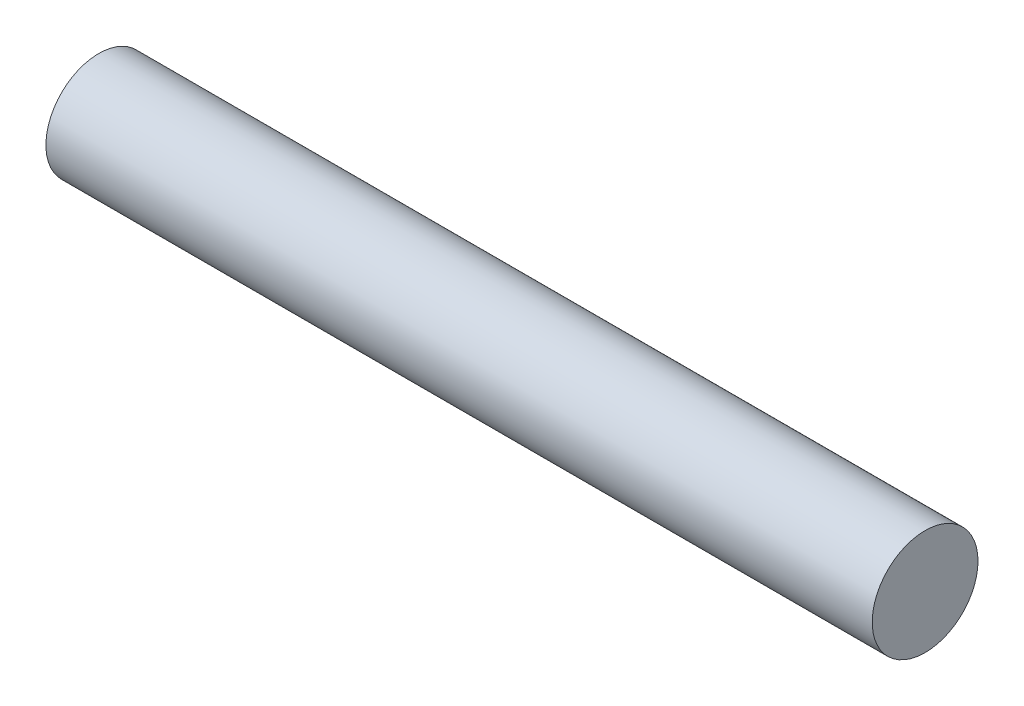
from build123d import *

# Parameters (mm, degrees)
SKETCH1_R           = 8.128
BOSS_EXTRUDE1_DEPTH = 127


with BuildPart() as part:
    # Sketch1 → Boss-Extrude1 (new body)
    with BuildSketch(Plane(origin=(0, 0, 0), x_dir=(0, 0, -1), z_dir=(1, 0, 0))):
        Circle(SKETCH1_R)
    extrude(amount=BOSS_EXTRUDE1_DEPTH)


solid = part.part
